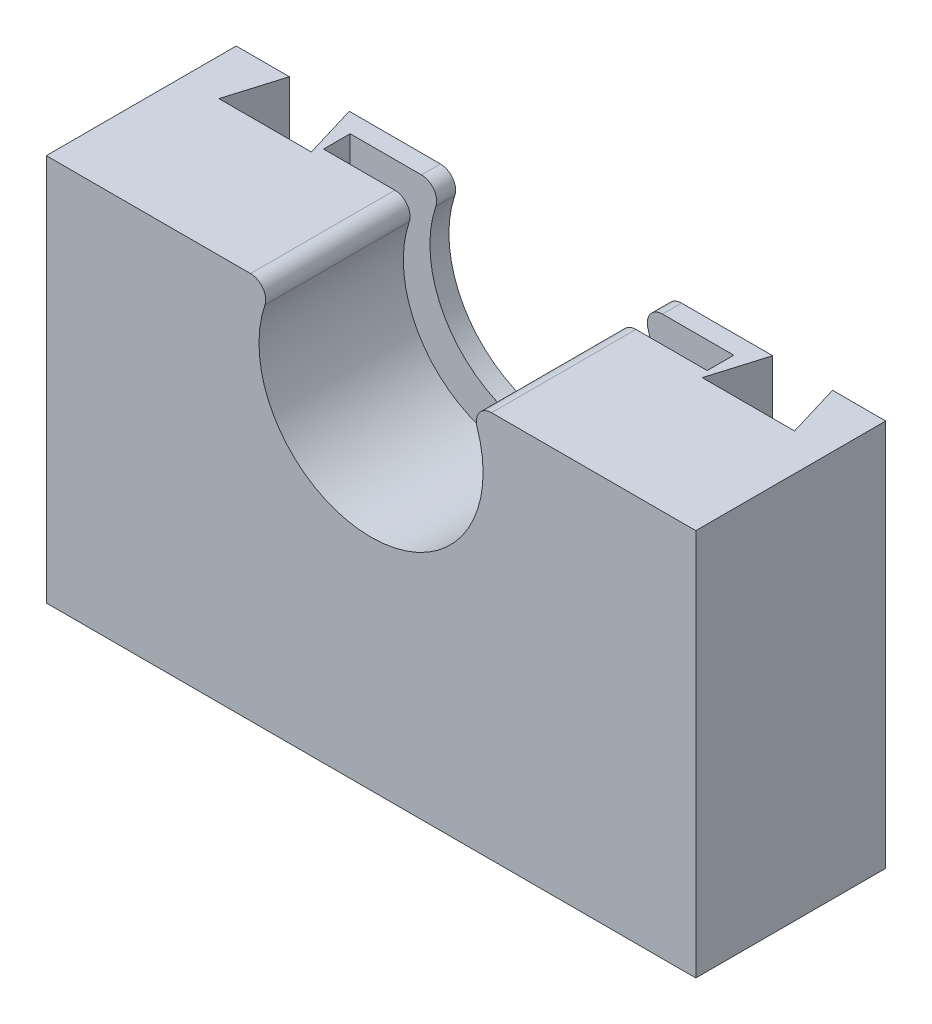
from build123d import *

# Parameters (mm, degrees)
BOSS_EXTRUDE1_DEPTH = 25
CUT_EXTRUDE3_START  = -25
SKETCH5_R           = 4.4
CUT_EXTRUDE3_DEPTH  = 4.8
CUT_EXTRUDE4_DEPTH  = 25
SKETCH8_W           = 50.5
SKETCH8_H           = 25.070079704
CUT_EXTRUDE5_DEPTH  = 3.5


with BuildPart() as part:
    # Sketch2 → Boss-Extrude1 (new body)
    with BuildSketch(Plane.XY):
        with BuildLine():
            Line((53.900497512, 28.014925373), (27.014667046, 28.014925373))
            ThreePointArc((27.014667046, 28.014925373), (25.389308303, 27.180347595), (25.120437848, 25.373134328))
            ThreePointArc((25.120437848, 25.373134328), (11.150497512, 5.889925373), (-2.819442823, 25.373134328))
            ThreePointArc((-2.819442823, 25.373134328), (-3.088313278, 27.180347595), (-4.713672021, 28.014925373))
            Line((-4.713672021, 28.014925373), (-31.599502488, 28.014925373))
            Line((-31.599502488, 28.014925373), (-31.599502488, -22.985074627))
            Line((-31.599502488, -22.985074627), (53.900497512, -22.985074627))
            Line((53.900497512, -22.985074627), (53.900497512, 28.014925373))
        make_face()
    extrude(amount=BOSS_EXTRUDE1_DEPTH)

    # Sketch5 → Cut-Extrude3 (cut)
    with BuildSketch(Plane.XY.offset(25).offset(CUT_EXTRUDE3_START)):
        with Locations((11.150497512, -2.910074627)):
            Circle(SKETCH5_R)
    extrude(amount=CUT_EXTRUDE3_DEPTH, mode=Mode.SUBTRACT)

    # Sketch6 → Cut-Extrude4 (cut)
    with BuildSketch(Plane(origin=(0, 28.014925373, 0), x_dir=(1, 0, 0), z_dir=(0, 1, 0))):
        Polygon((-24.599502488, 0), (-26.73851519, -7.13632431), (-14.574659319, -7.13632431), (-16.713672021, 0), align=None)
        Polygon((46.900497512, 0), (49.040087925, -7.136151124), (36.875076634, -7.136151124), (39.014667046, 0), align=None)
    extrude(amount=-CUT_EXTRUDE4_DEPTH, mode=Mode.SUBTRACT)

    # Sketch8 → Cut-Extrude5 (cut)
    with BuildSketch(Plane(origin=(0, 0, 2.5), x_dir=(-1, 0, 0), z_dir=(0, 0, -1))):
        with Locations((-11.150497512, 15.479885521)):
            Rectangle(SKETCH8_W, SKETCH8_H)
    extrude(amount=-CUT_EXTRUDE5_DEPTH, mode=Mode.SUBTRACT)


solid = part.part
